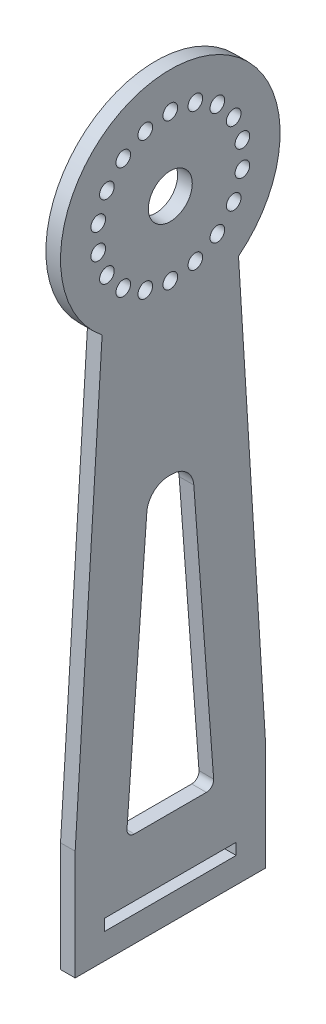
from build123d import *

# Parameters (mm, degrees)
RESSALTO_EXTRUS_O1_DEPTH = 2
ESBO_O2_R                = 3
ESBO_O2_R_2              = 1
CORTE_EXTRUS_O1_DEPTH    = 2
PADR_OCIRCULAR1_COUNT    = 18
ESBO_O3_W                = 18
ESBO_O3_H                = 1.561418551
CORTE_EXTRUS_O2_DEPTH    = 2


with BuildPart() as part:
    # Esboço1 → Ressalto-extrusão1 (new body)
    with BuildSketch(Plane(origin=(0, 0, 0), x_dir=(0, 0, -1), z_dir=(1, 0, 0))):
        with BuildLine():
            Line((-13, -71), (-13, -86))
            Line((-13, -86), (0, -86))
            Line((0, -86), (0, 15))
            ThreePointArc((0, 15), (-14.165790836, 4.932582487), (-9.316524238, -11.755950669))
            add(Edge.make_bspline(
                [(-9.316524238, -11.755950669), (-13, -71)],
                knots=[0, 0, 1, 1], degree=1))
        make_face()
    ressalto_extrus_o1 = extrude(amount=RESSALTO_EXTRUS_O1_DEPTH)

    # Espelhar1: Ressalto-extrusão1 across plane
    add(ressalto_extrus_o1.mirror(Plane(origin=(2, 15, 0), x_dir=(1, 0, 0), z_dir=(0, 0, 1))))

    # Esboço2 → Corte-extrusão1 (cut)
    with BuildSketch(Plane(origin=(2, 0, 0), x_dir=(0, 0, -1), z_dir=(1, 0, 0))):
        Circle(ESBO_O2_R)
        with Locations((0, -10)):
            Circle(ESBO_O2_R_2)
    corte_extrus_o1 = extrude(amount=-CORTE_EXTRUS_O1_DEPTH, mode=Mode.SUBTRACT)

    # PadrãoCircular1: Corte-extrusão1 ×18 about axis
    padr_ocircular1_axis = Axis((0, 0, 0), (1, 0, 0))
    for i in range(1, PADR_OCIRCULAR1_COUNT):
        add(corte_extrus_o1.rotate(padr_ocircular1_axis, i * 360 / PADR_OCIRCULAR1_COUNT), mode=Mode.SUBTRACT)

    # Esboço3 → Corte-extrusão2 (cut)
    with BuildSketch(Plane(origin=(2, 0, 0), x_dir=(0, 0, -1), z_dir=(1, 0, 0))):
        with BuildLine():
            Line((-4.922191444, -73), (4.922191444, -73))
            ThreePointArc((4.922191444, -73), (5.655263728, -72.680150738), (5.919390754, -71.925210052))
            Line((5.919390754, -71.925210052), (3.208172262, -35.775630155))
            ThreePointArc((3.208172262, -35.775630155), (2.257026545, -33.800783147), (0.216574332, -33))
            Line((0.216574332, -33), (-0.216574332, -33))
            ThreePointArc((-0.216574332, -33), (-2.257026545, -33.800783147), (-3.208172262, -35.775630155))
            Line((-3.208172262, -35.775630155), (-5.919390754, -71.925210052))
            ThreePointArc((-5.919390754, -71.925210052), (-5.655263728, -72.680150738), (-4.922191444, -73))
        make_face()
        with Locations((0, -81.719290725)):
            Rectangle(ESBO_O3_W, ESBO_O3_H)
    extrude(amount=-CORTE_EXTRUS_O2_DEPTH, mode=Mode.SUBTRACT)


solid = part.part
